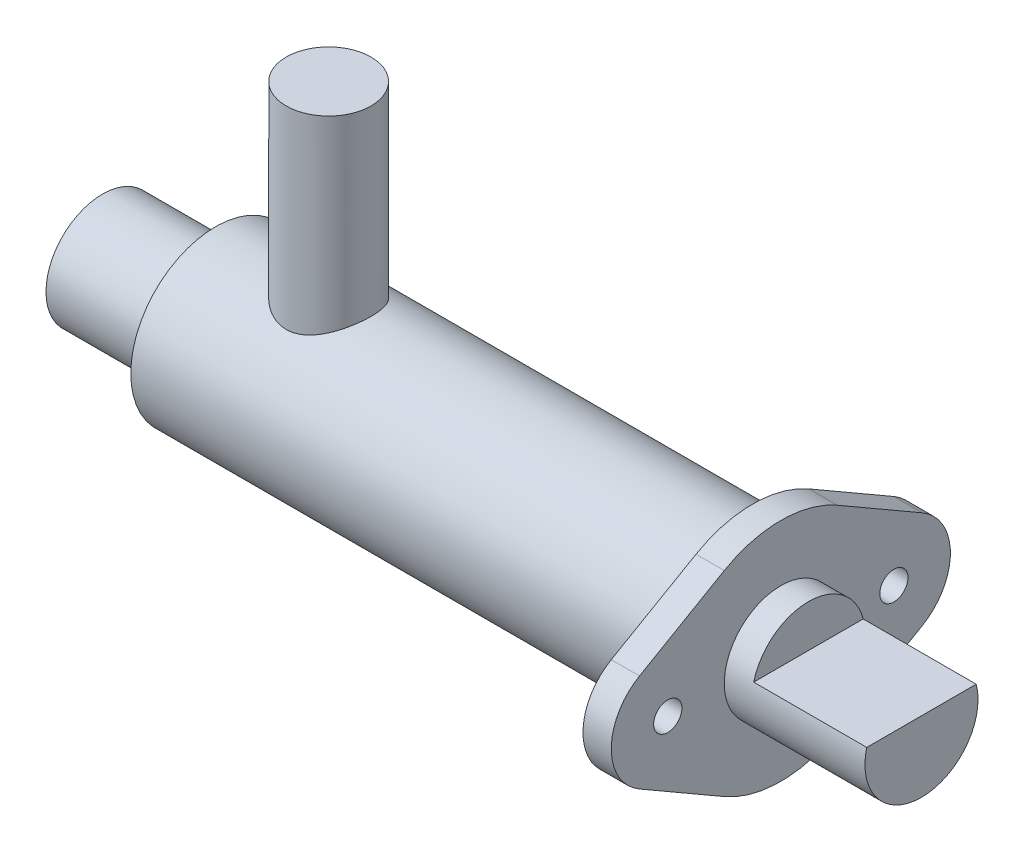
from build123d import *

# Parameters (mm, degrees)
SKETCH7_R           = 1.5875
BOSS_EXTRUDE2_DEPTH = 3.175
SKETCH5_R           = 6.35
CUT_EXTRUDE1_DEPTH  = 41.348883888
SKETCH8_R           = 6.35
EXTRUDE1_DEPTH      = 57.15
CUT_EXTRUDE2_DEPTH  = 12.7
SKETCH10_R          = 4.7625
EXTRUDE2_DEPTH      = 30


with BuildPart() as part:
    # Sketch4 → Boss-Revolve2 (revolve)
    with BuildSketch(Plane.XY):
        Polygon((-47.625, 0), (-47.625, -6.35), (-34.925, -6.35), (-34.925, -9.525), (28.575, -9.525), (28.575, 0), align=None)
    revolve(axis=Axis((-47.625, 0, 0), (1, 0, 0)))

    # Sketch7 → Boss-Extrude2 (add)
    with BuildSketch(Plane(origin=(28.575, 29.318732004, 10.174246846), x_dir=(0, 0.707106781, -0.707106781), z_dir=(1, 0, 0))):
        with BuildLine():
            Line((-20.873950462, -12.811868036), (-10.250193405, -15.65849516))
            ThreePointArc((-10.250193405, -15.65849516), (-4.556939156, -18.945497033), (-1.269937284, -24.638751281))
            Line((-1.269937284, -24.638751281), (1.57668984, -35.262508339))
            ThreePointArc((1.57668984, -35.262508339), (-0.066811096, -41.396137336), (-6.200440093, -43.039638272))
            Line((-6.200440093, -43.039638272), (-16.82419715, -40.193011148))
            ThreePointArc((-16.82419715, -40.193011148), (-22.517451399, -36.906009275), (-25.804453271, -31.212755027))
            Line((-25.804453271, -31.212755027), (-28.651080396, -20.588997969))
            ThreePointArc((-28.651080396, -20.588997969), (-27.007579459, -14.455368972), (-20.873950462, -12.811868036))
        make_face()
        with Locations((-22.517451399, -18.945497033)):
            Circle(SKETCH7_R, mode=Mode.SUBTRACT)
        with Locations((-4.556939156, -36.906009275)):
            Circle(SKETCH7_R, mode=Mode.SUBTRACT)
    extrude(amount=-BOSS_EXTRUDE2_DEPTH)

    # Sketch5 → Cut-Extrude1 (cut)
    with BuildSketch(Plane(origin=(28.575, 0, 0), x_dir=(0, 0, -1), z_dir=(1, 0, 0))):
        Circle(SKETCH5_R)
    extrude(amount=-CUT_EXTRUDE1_DEPTH, mode=Mode.SUBTRACT)

    # Sketch8 → Extrude1 (add)
    with BuildSketch(Plane(origin=(-12.773883888, 0, 0), x_dir=(0, 0, -1), z_dir=(1, 0, 0))):
        Circle(SKETCH8_R)
    extrude(amount=EXTRUDE1_DEPTH)

    # Sketch9 → Cut-Extrude2 (cut)
    with BuildSketch(Plane(origin=(44.376116112, 0, 0), x_dir=(0, 0, -1), z_dir=(1, 0, 0))):
        with BuildLine():
            Line((-6.148361062, 1.5875), (6.148361062, 1.5875))
            ThreePointArc((6.148361062, 1.5875), (0, 6.35), (-6.148361062, 1.5875))
        make_face()
    extrude(amount=-CUT_EXTRUDE2_DEPTH, mode=Mode.SUBTRACT)

    # Sketch10 → Extrude2 (add)
    with BuildSketch(Plane(origin=(0, 0, 0), x_dir=(1, 0, 0), z_dir=(0, 1, 0))):
        with Locations((-22.225, 0)):
            Circle(SKETCH10_R)
    extrude(amount=EXTRUDE2_DEPTH)


solid = part.part
